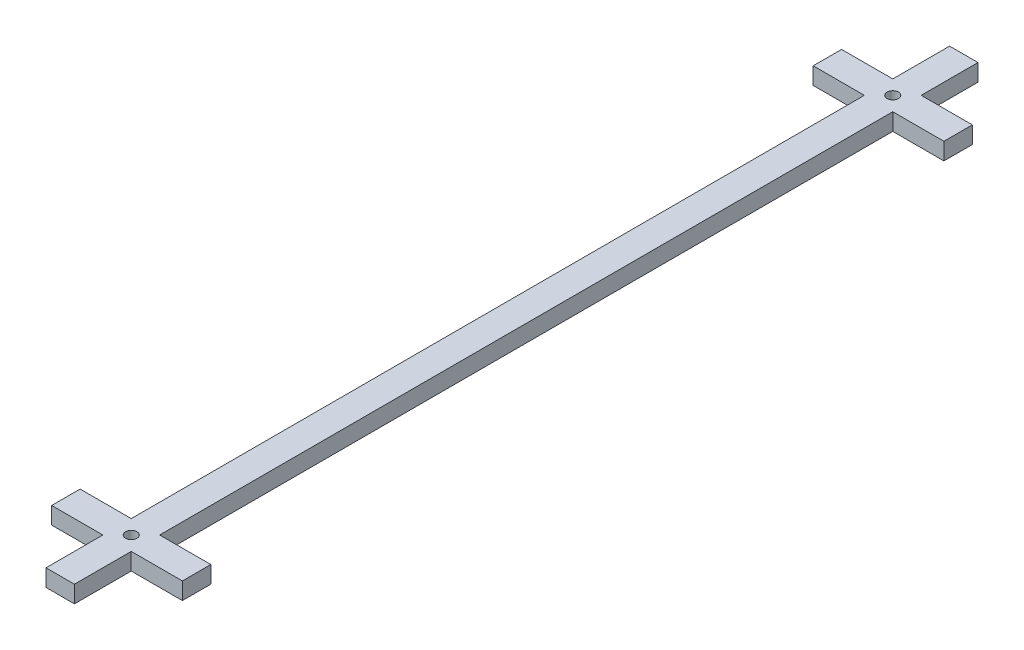
from build123d import *

# Parameters (mm, degrees)
SKETCH1_W           = 5
SKETCH1_H           = 159
BOSS_EXTRUDE1_DEPTH = 3
SKETCH3_W           = 23
SKETCH3_H           = 5
BOSS_EXTRUDE2_DEPTH = 3
SKETCH5_R           = 1
CUT_EXTRUDE4_DEPTH  = 3


with BuildPart() as part:
    # Sketch1 → Boss-Extrude1 (new body)
    with BuildSketch(Plane(origin=(0, 0, 0), x_dir=(1, 0, 0), z_dir=(0, 1, 0))):
        with Locations((2.5, 79.5)):
            Rectangle(SKETCH1_W, SKETCH1_H)
    extrude(amount=BOSS_EXTRUDE1_DEPTH)

    # Sketch3 → Boss-Extrude2 (add)
    with BuildSketch(Plane(origin=(0, 0, 0), x_dir=(1, 0, 0), z_dir=(0, 1, 0))):
        with Locations((2.5, 12.5)):
            Rectangle(SKETCH3_W, SKETCH3_H)
        with Locations((2.5, 146.5)):
            Rectangle(SKETCH3_W, SKETCH3_H)
    extrude(amount=BOSS_EXTRUDE2_DEPTH)

    # Sketch5 → Cut-Extrude4 (cut)
    with BuildSketch(Plane(origin=(0, 0, 0), x_dir=(1, 0, 0), z_dir=(0, 1, 0))):
        with Locations((2.5, 12.5)):
            Circle(SKETCH5_R)
        with Locations((2.5, 146.5)):
            Circle(SKETCH5_R)
    extrude(amount=CUT_EXTRUDE4_DEPTH, mode=Mode.SUBTRACT)


solid = part.part
